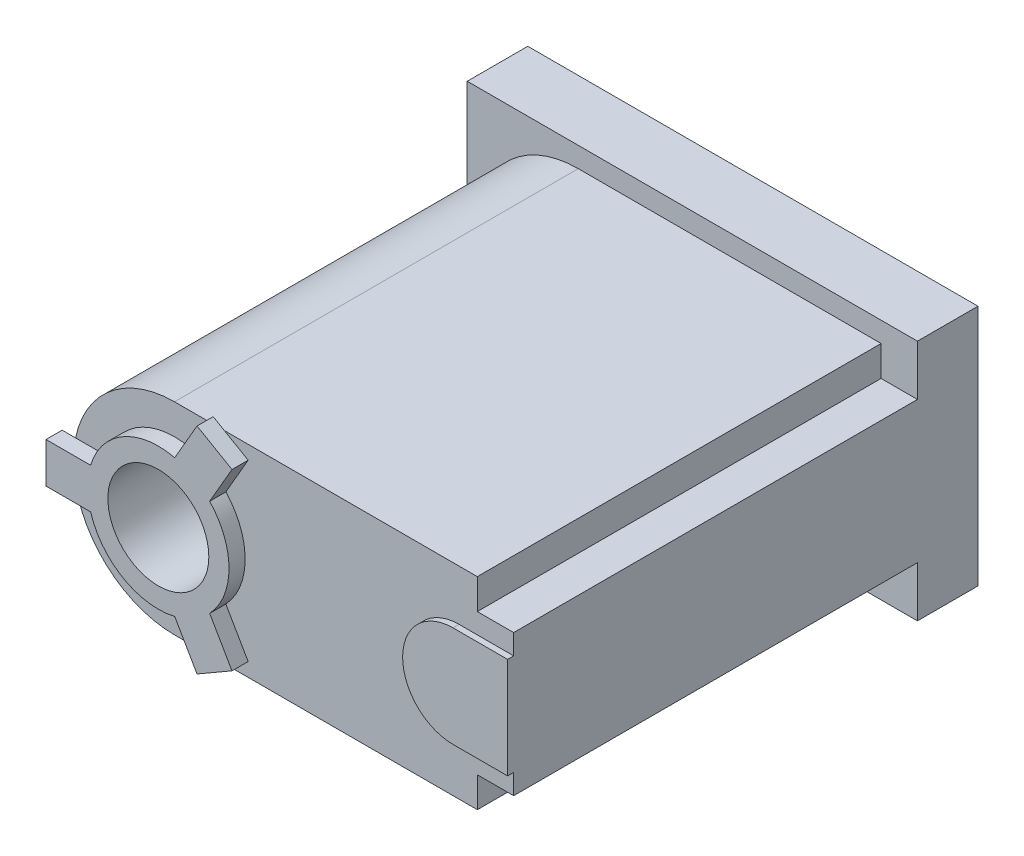
from build123d import *

# Parameters (mm, degrees)
SKETCH_1_R      = 25
EXTRUDE_1_DEPTH = 230
SKETCH_2_W      = 230
SKETCH_2_H      = 70
EXTRUDE_2_DEPTH = 18
SKETCH_3_W      = 223
SKETCH_3_H      = 120
EXTRUDE_3_DEPTH = 30
EXTRUDE_4_DEPTH = 3
SKETCH_5_R      = 25
EXTRUDE_5_DEPTH = 8


with BuildPart() as part:
    # 草图1 → 凸台-拉伸1 (new body)
    with BuildSketch(Plane.XY):
        with BuildLine():
            Line((0, 50), (150, 50))
            Line((150, 50), (150, -50))
            Line((150, -50), (0, -50))
            ThreePointArc((0, -50), (-50, 0), (0, 50))
        make_face()
        Circle(SKETCH_1_R, mode=Mode.SUBTRACT)
    extrude(amount=EXTRUDE_1_DEPTH)

    # 草图2 → 凸台-拉伸2 (add)
    with BuildSketch(Plane(origin=(150, 0, 0), x_dir=(0, 0, -1), z_dir=(1, 0, 0))):
        with Locations((-115, 0)):
            Rectangle(SKETCH_2_W, SKETCH_2_H)
    extrude(amount=EXTRUDE_2_DEPTH)

    # 草图3 → 凸台-拉伸3 (add)
    with BuildSketch(Plane(origin=(0, 0, 0), x_dir=(-1, 0, 0), z_dir=(0, 0, -1))):
        with Locations((-56.5, 0)):
            Rectangle(SKETCH_3_W, SKETCH_3_H)
    extrude(amount=-EXTRUDE_3_DEPTH)

    # 草图4 → 凸台-拉伸4 (add)
    with BuildSketch(Plane.XY.offset(230)):
        with BuildLine():
            Line((168, 25), (141, 25))
            ThreePointArc((141, 25), (116, 0), (141, -25))
            Line((141, -25), (168, -25))
            Line((168, -25), (168, 25))
        make_face()
    extrude(amount=EXTRUDE_4_DEPTH)

    # 草图5 → 凸台-拉伸5 (add)
    with BuildSketch(Plane.XY.offset(230)):
        with BuildLine():
            Line((-55.646359671, 10), (-55.646359671, -10))
            Line((-55.646359671, -10), (-33.541019662, -10))
            ThreePointArc((-33.541019662, -10), (-17.5, -30.310889132), (8.110255793, -34.047375097))
            Line((8.110255793, -34.047375097), (19.162925798, -53.191161103))
            Line((19.162925798, -53.191161103), (36.483433873, -43.191161103))
            Line((36.483433873, -43.191161103), (25.430763869, -24.047375097))
            ThreePointArc((25.430763869, -24.047375097), (35, 0), (25.430763869, 24.047375097))
            Line((25.430763869, 24.047375097), (36.483433873, 43.191161103))
            Line((36.483433873, 43.191161103), (19.162925798, 53.191161103))
            Line((19.162925798, 53.191161103), (8.110255793, 34.047375097))
            ThreePointArc((8.110255793, 34.047375097), (-17.5, 30.310889132), (-33.541019662, 10))
            Line((-33.541019662, 10), (-55.646359671, 10))
        make_face()
        Circle(SKETCH_5_R, mode=Mode.SUBTRACT)
    extrude(amount=EXTRUDE_5_DEPTH)


solid = part.part
